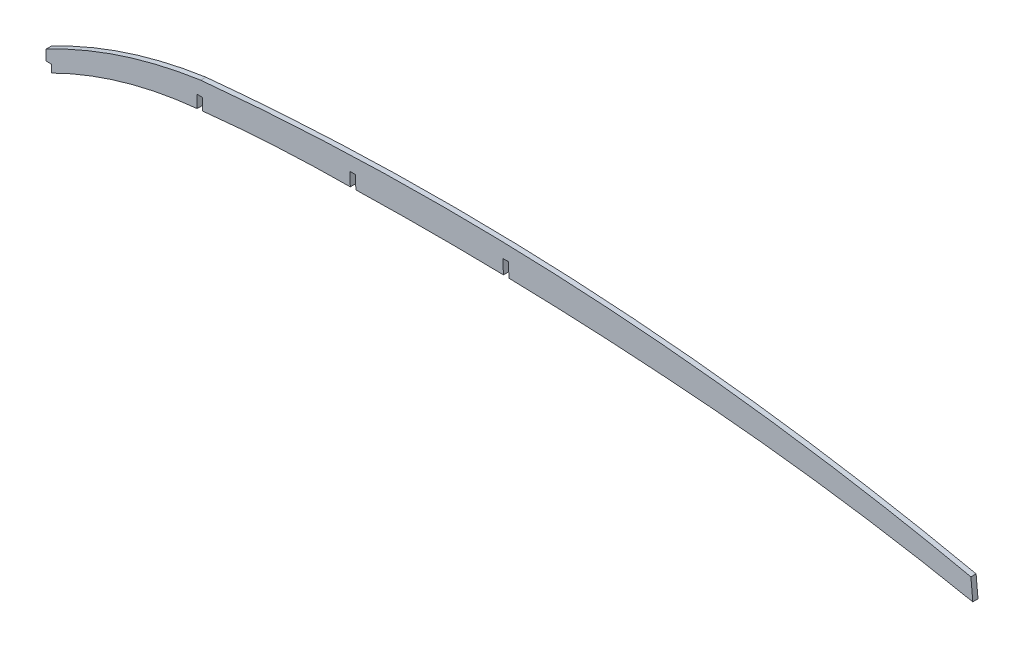
from build123d import *

# Parameters (mm, degrees)
BOSS_EXTRUDE1_DEPTH = 1.5875
SKETCH2_W           = 3.3528
SKETCH2_H           = 6.4262
SKETCH2_W_2         = 3.3782
SKETCH2_H_2         = 12.7
CUT_EXTRUDE1_DEPTH  = 583.351362494


with BuildPart() as part:
    # Sketch1 → Boss-Extrude1 (new, symmetric)
    with BuildSketch(Plane.XY):
        with BuildLine():
            Line((0, 98.650251409), (0, 85.942482804))
            ThreePointArc((0, 85.942482804), (44.883725347, 104.075777355), (92.3925, 113.364561093))
            ThreePointArc((92.3925, 113.364561093), (139.073495573, 117.280297245), (185.895946704, 118.731643998))
            ThreePointArc((185.895946704, 118.731643998), (279.546572247, 118.92726657), (373.101055052, 114.68030529))
            ThreePointArc((373.101055052, 114.68030529), (470.024153779, 105.277769076), (566.085246422, 89.31652744))
            Line((566.085246422, 89.31652744), (564.932089986, 101.967475673))
            add(Edge.make_bspline(
                [(564.932089986, 101.967475673), (526.305455218, 110.35905311), (487.405693808, 117.234860687), (438.439550099, 123.934721128), (428.624759847, 125.180263294), (408.998984047, 127.476820047), (399.18472115, 128.528373058), (369.737829992, 131.394440576), (350.101100844, 132.920474645), (291.174630327, 136.353130053), (251.868630305, 137.116022476), (173.213311456, 135.594508668), (133.863993721, 133.310179259), (94.492645692, 129.476109839)],
                knots=[0, 0, 0, 0, 0.25, 0.25, 0.3125, 0.3125, 0.375, 0.375, 0.5, 0.5, 0.75, 0.75, 1, 1, 1, 1], degree=3))
            ThreePointArc((94.492645692, 129.476109839), (45.925545315, 118.111851759), (0, 98.650251409))
        make_face()
    extrude(amount=BOSS_EXTRUDE1_DEPTH, both=True)

    # Sketch2 → Cut-Extrude1 (cut, through all)
    with BuildSketch(Plane.XY.offset(1.5875)):
        with Locations((1.6764, 89.155582804)):
            Rectangle(SKETCH2_W, SKETCH2_H)
        with Locations((93.98, 114.558722781)):
            Rectangle(SKETCH2_W_2, SKETCH2_H_2)
        Polygon((185.684391149, 126.782012482), (189.061851112, 126.852719214), (189.327665893, 114.15550131), (185.950205931, 114.084794578), align=None)
        Polygon((279.023773174, 127.416061043), (282.398848572, 127.561323909), (282.944949573, 114.873070535), (279.569874175, 114.727807668), align=None)
    extrude(amount=-CUT_EXTRUDE1_DEPTH, mode=Mode.SUBTRACT)


solid = part.part
